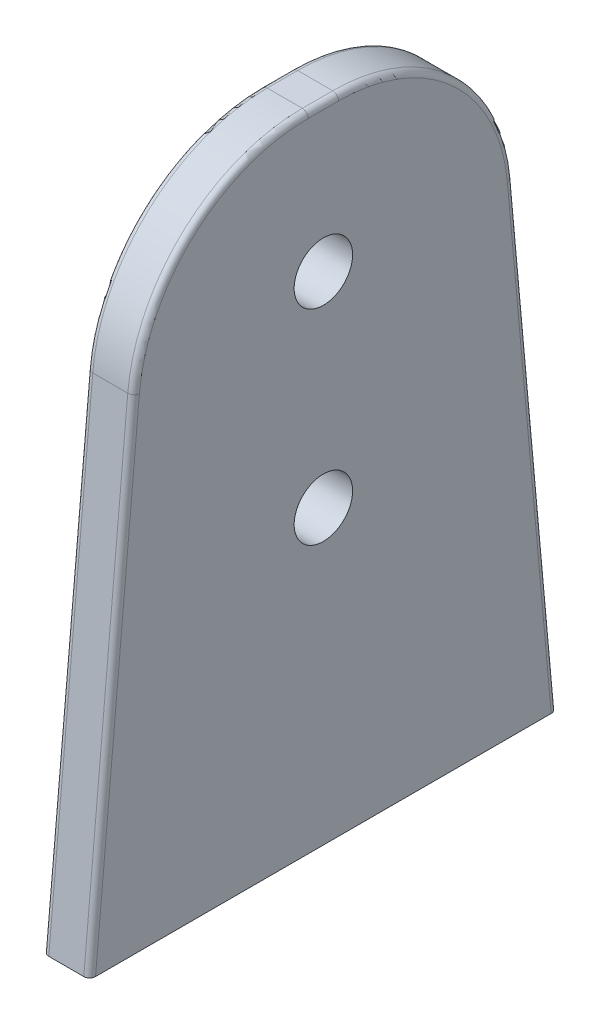
from build123d import *

# Parameters (mm, degrees)
SKICA1_R                = 5
P_IDAT_VYSUNUT_M1_DEPTH = 8
ZAOBLIT1_R              = 30
ZAOBLIT2_R              = 1


with BuildPart() as part:
    # Skica1 → Přidat vysunutím1 (new body)
    with BuildSketch(Plane(origin=(0, 0, 0), x_dir=(0, 0, -1), z_dir=(1, 0, 0))):
        Polygon((-30, 110), (30, 110), (40, 0), (-40, 0), align=None)
        with Locations((0, 85)):
            Circle(SKICA1_R, mode=Mode.SUBTRACT)
        with Locations((0, 50)):
            Circle(SKICA1_R, mode=Mode.SUBTRACT)
    extrude(amount=P_IDAT_VYSUNUT_M1_DEPTH)

    # Zaoblit1
    zaoblit1_edges = [part.edges().sort_by_distance(p)[0] for p in [
        (4, 110, 30),
        (4, 110, -30),
    ]]
    fillet(zaoblit1_edges, radius=ZAOBLIT1_R)

    # Zaoblit2
    zaoblit2_edges = [part.edges().sort_by_distance(p)[0] for p in [
        (0, 110, 0),
        (8, 110, 0),
        (0, 41.358036191, 36.240178528),
        (0, 102.152676717, 22.833709509),
        (0, 102.152676717, -22.833709509),
        (8, 41.358036191, 36.240178528),
        (8, 102.152676717, 22.833709509),
        (8, 102.152676717, -22.833709509),
        (8, 41.358036191, -36.240178528),
        (0, 41.358036191, -36.240178528),
    ]]
    fillet(zaoblit2_edges, radius=ZAOBLIT2_R)


solid = part.part
